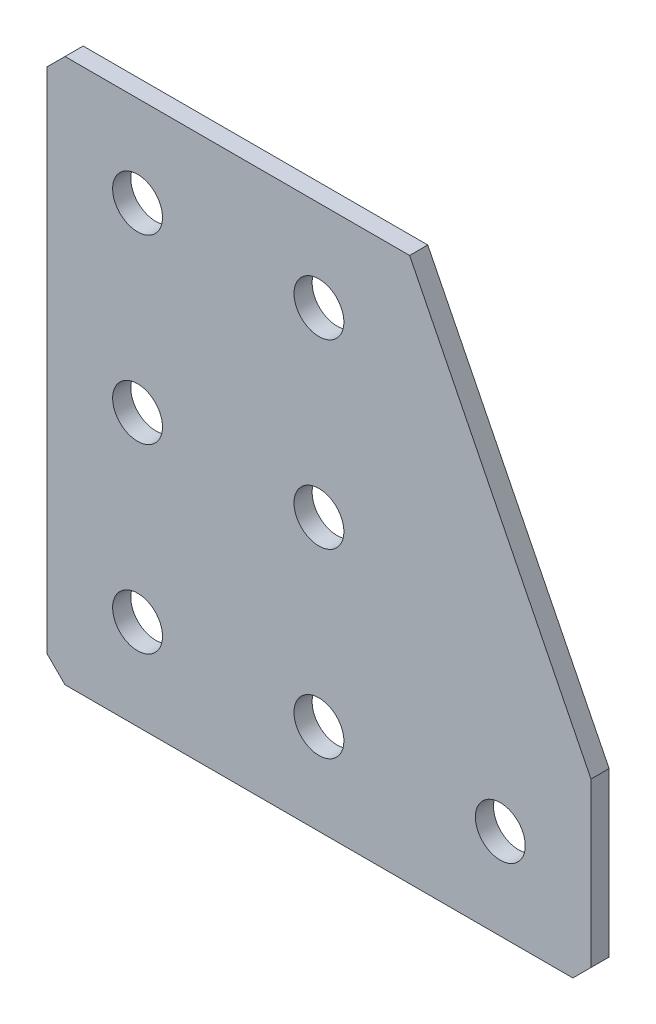
from build123d import *

# Parameters (mm, degrees)
EXTRUDE_1_DEPTH   = 2
HOLE_WIZARD_M51_D = 5.5
CHAMFER_1_SIZE    = 2


with BuildPart() as part:
    # Эскиз1 → Бобышка-Вытянуть1 (new body)
    with BuildSketch(Plane(origin=(0, 0, 0), x_dir=(1, 0, 0), z_dir=(0, 0, -1))):
        Polygon((0, 0), (0, 60), (60, 60), (60, 40), (40, 0), align=None)
    extrude(amount=EXTRUDE_1_DEPTH)

    # Отверстие с зазором M51 (through all)
    with Locations(Plane(origin=(0, 0, -2), x_dir=(1, 0, 0), z_dir=(0, 0, -1))):
        with Locations((30, 50), (10, 50), (10, 30), (10, 10), (50, 50), (30, 30), (30, 10)):
            Hole(HOLE_WIZARD_M51_D / 2)

    # Фаска1
    chamfer_1_edges = [part.edges().sort_by_distance(p)[0] for p in [
        (0, 0, -1),
        (0, -60, -1),
        (60, -60, -1),
    ]]
    chamfer(chamfer_1_edges, length=CHAMFER_1_SIZE)


solid = part.part
